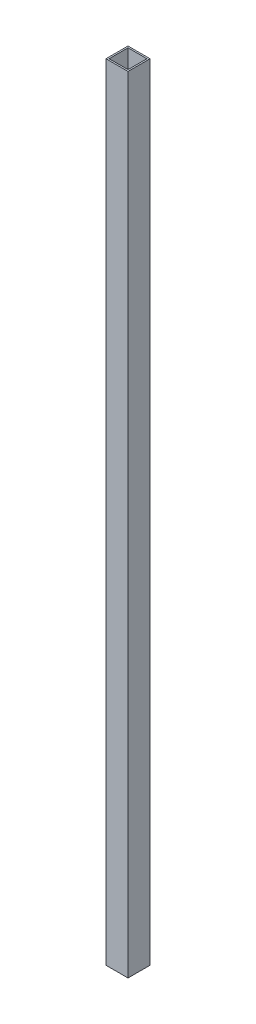
from build123d import *

# Parameters (mm, degrees)
SKETCH1_W           = 17
SKETCH1_H           = 17
SKETCH1_W_2         = 14.6
SKETCH1_H_2         = 14.6
BOSS_EXTRUDE1_DEPTH = 606


with BuildPart() as part:
    # Sketch1 → Boss-Extrude1 (new body)
    with BuildSketch(Plane(origin=(0, 0, 0), x_dir=(1, 0, 0), z_dir=(0, 1, 0))):
        Rectangle(SKETCH1_W, SKETCH1_H)
        Rectangle(SKETCH1_W_2, SKETCH1_H_2, mode=Mode.SUBTRACT)
    extrude(amount=BOSS_EXTRUDE1_DEPTH)


solid = part.part
